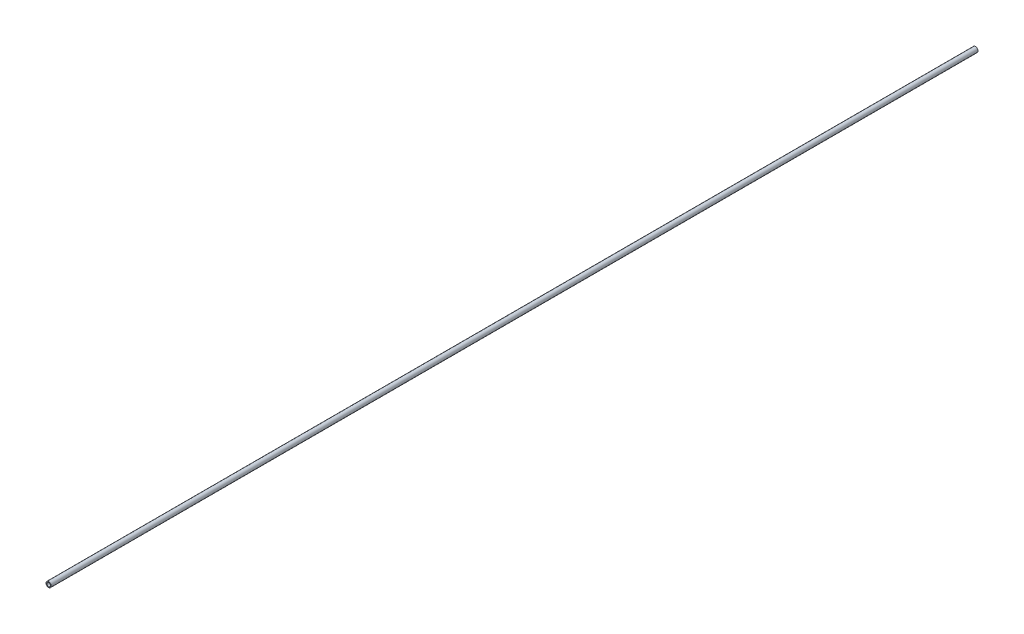
from build123d import *

# Parameters (mm, degrees)
SKETCH2_R                = 6.83635542
SKETCH2_R_2              = 4.83635542
BOSS_EXTRUDE1_DEPTH      = 1229.528888
BOSS_EXTRUDE1_DEPTH_BACK = 1229.528888


with BuildPart() as part:
    # Sketch2 → Boss-Extrude1 (new body, two sides)
    with BuildSketch(Plane.XY) as boss_extrude1_sk:
        Circle(SKETCH2_R)
        Circle(SKETCH2_R_2, mode=Mode.SUBTRACT)
    extrude(amount=BOSS_EXTRUDE1_DEPTH)
    extrude(boss_extrude1_sk.sketch, amount=-BOSS_EXTRUDE1_DEPTH_BACK)


solid = part.part
